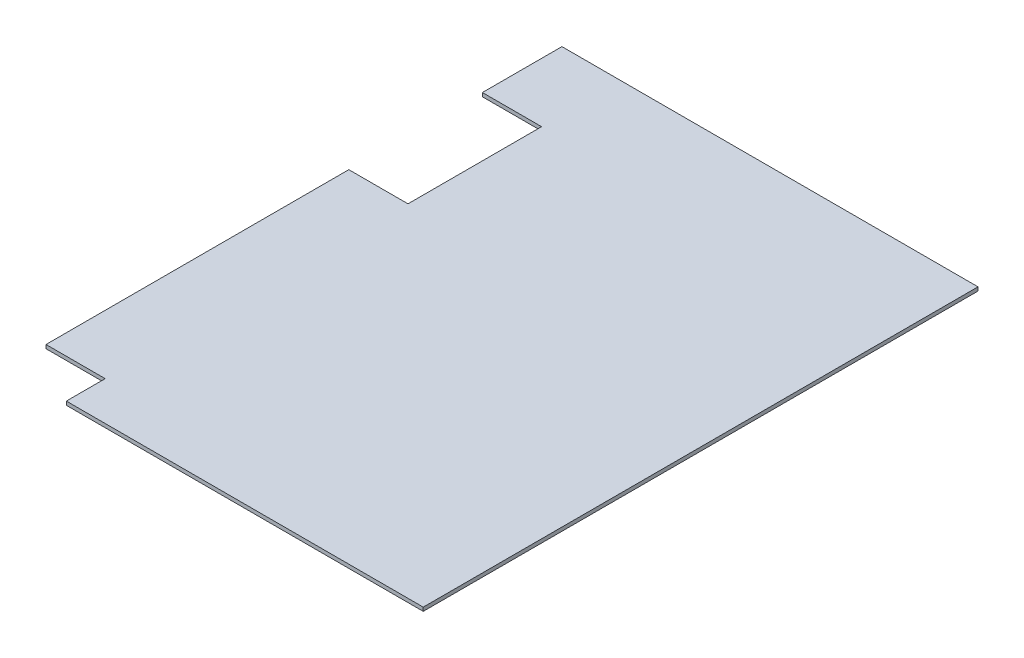
from build123d import *

# Parameters (mm, degrees)
BOSS_EXTRUDE2_DEPTH = 50.8


with BuildPart() as part:
    # Sketch1 → Boss-Extrude2 (new body)
    with BuildSketch(Plane(origin=(0, 0, 0), x_dir=(1, 0, 0), z_dir=(0, 1, 0))):
        Polygon((-2044.7, 882.65), (-2857.5, 882.65), (-2857.5, -3276.6), (-2044.7, -3276.6), (-2044.7, -3810), (2857.5, -3810), (2857.5, 3810), (-2857.5, 3810), (-2857.5, 2717.8), (-2044.7, 2717.8), align=None)
    extrude(amount=BOSS_EXTRUDE2_DEPTH)


solid = part.part
